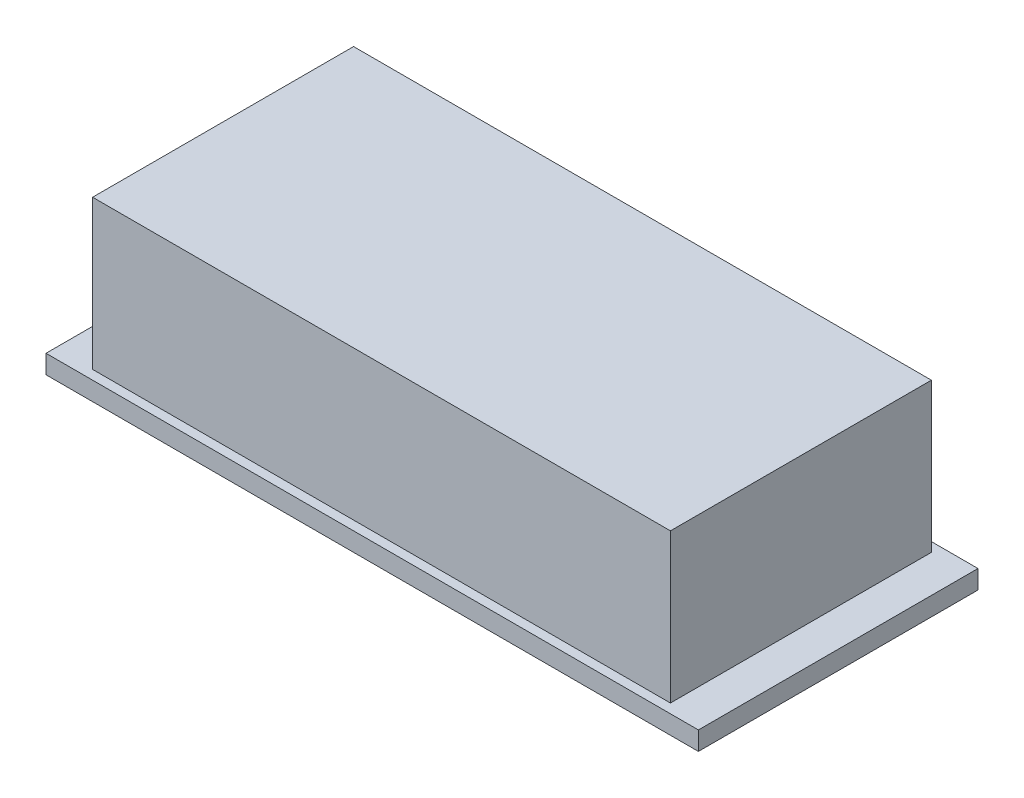
from build123d import *

# Parameters (mm, degrees)
ESQUISSE1_W        = 70
ESQUISSE1_H        = 30
BOSS_EXTRU_1_DEPTH = 2
ESQUISSE2_W        = 62
ESQUISSE2_H        = 28
BOSS_EXTRU_2_DEPTH = 16


with BuildPart() as part:
    # Esquisse1 → Boss.-Extru.1 (new body)
    with BuildSketch(Plane(origin=(0, 0, 0), x_dir=(1, 0, 0), z_dir=(0, 1, 0))):
        with Locations((35, 15)):
            Rectangle(ESQUISSE1_W, ESQUISSE1_H)
    extrude(amount=BOSS_EXTRU_1_DEPTH)

    # Esquisse2 → Boss.-Extru.2 (add)
    with BuildSketch(Plane(origin=(0, 2, 0), x_dir=(1, 0, 0), z_dir=(0, 1, 0))):
        with Locations((35, 15)):
            Rectangle(ESQUISSE2_W, ESQUISSE2_H)
    extrude(amount=BOSS_EXTRU_2_DEPTH)


solid = part.part
